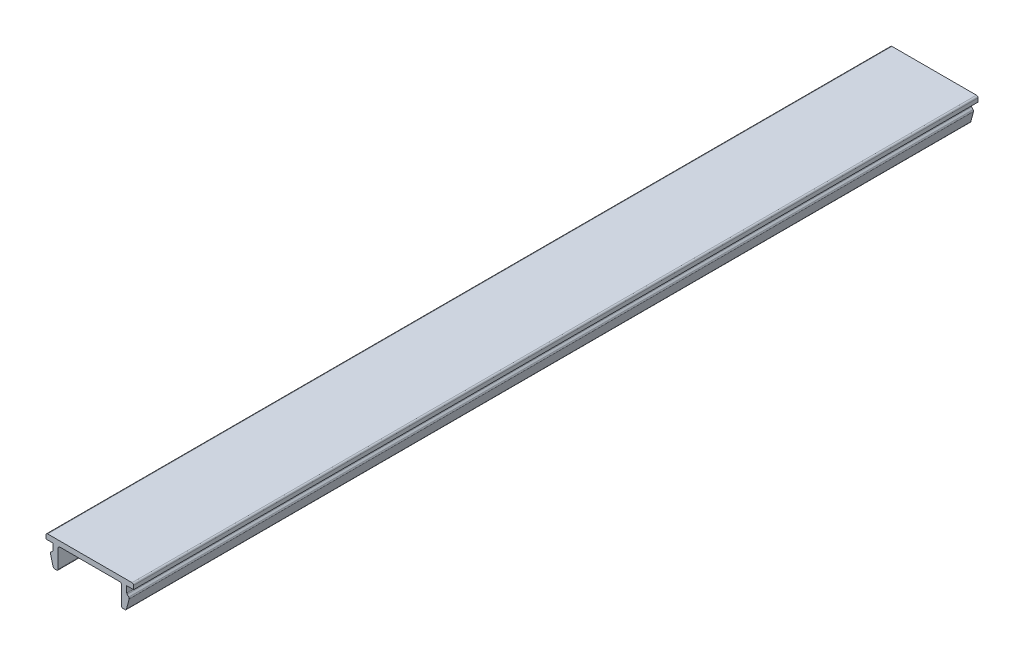
from build123d import *

# Parameters (mm, degrees)
BOSS_EXTRUDE1_DEPTH = 160
FILLET1_R           = 0.3


with BuildPart() as part:
    # Sketch1 → Boss-Extrude1 (new body)
    with BuildSketch(Plane.XY):
        Polygon((-8.3, 1), (8.3, 1), (8.3, 0), (7, 0), (7, -1.3), (7.5, -1.8), (6.883716857, -4.1), (6, -4.1), (6, 0), (-6, 0), (-6, -4.1), (-6.883716857, -4.1), (-7.5, -1.8), (-7, -1.3), (-7, 0), (-8.3, 0), align=None)
    extrude(amount=BOSS_EXTRUDE1_DEPTH)

    # Fillet1
    fillet1_edges = [part.edges().sort_by_distance(p)[0] for p in [
        (-8.3, 1, 80),
        (8.3, 1, 80),
        (7, -1.3, 80),
        (7.5, -1.8, 80),
        (6.883716857, -4.1, 80),
        (6, -4.1, 80),
        (6, 0, 80),
        (-6, 0, 80),
        (-6, -4.1, 80),
        (-6.883716857, -4.1, 80),
        (-7.5, -1.8, 80),
        (-7, -1.3, 80),
    ]]
    fillet(fillet1_edges, radius=FILLET1_R)


solid = part.part
